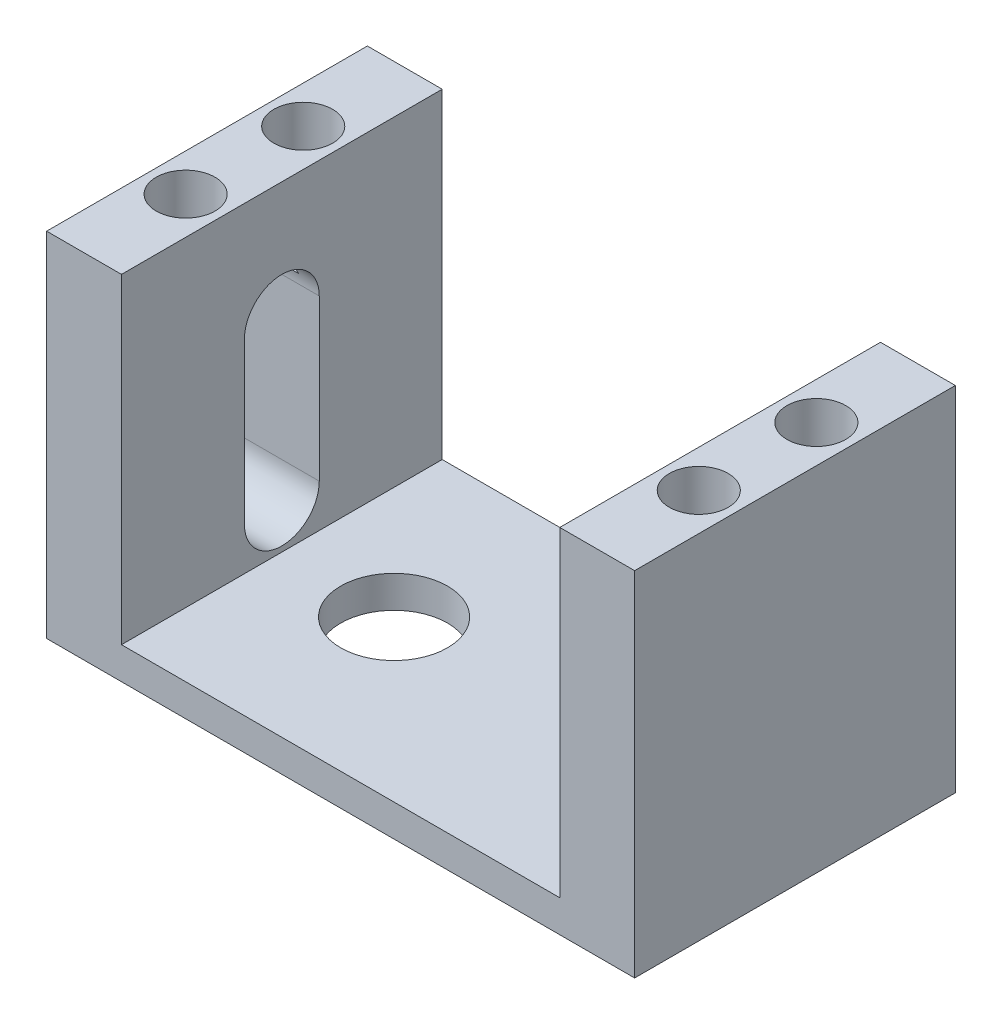
from build123d import *

# Parameters (mm, degrees)
SKETCH1_W           = 55
SKETCH1_H           = 30
BOSS_EXTRUDE1_DEPTH = 3
SKETCH2_W           = 7
SKETCH2_H           = 30
BOSS_EXTRUDE2_DEPTH = 30
SKETCH3_R           = 2.75
CUT_EXTRUDE1_DEPTH  = 10
CUT_EXTRUDE2_REACH  = 57
CUT_EXTRUDE3_REACH  = 35
SKETCH5_R           = 5


with BuildPart() as part:
    # Sketch1 → Boss-Extrude1 (new body)
    with BuildSketch(Plane(origin=(0, 0, 0), x_dir=(1, 0, 0), z_dir=(0, 1, 0))):
        Rectangle(SKETCH1_W, SKETCH1_H)
    extrude(amount=BOSS_EXTRUDE1_DEPTH)

    # Sketch2 → Boss-Extrude2 (add)
    with BuildSketch(Plane(origin=(0, 3, 0), x_dir=(1, 0, 0), z_dir=(0, 1, 0))):
        Polygon((-27.5, -12), (-27.5, -15), (-20.5, -15), (-20.5, 15), (-27.5, 15), align=None)
        with Locations((24, 0)):
            Rectangle(SKETCH2_W, SKETCH2_H)
    extrude(amount=BOSS_EXTRUDE2_DEPTH)

    # Sketch3 → Cut-Extrude1 (cut)
    with BuildSketch(Plane(origin=(0, 33, 0), x_dir=(1, 0, 0), z_dir=(0, 1, 0))):
        with Locations((-24, 5.5)):
            Circle(SKETCH3_R)
        with Locations((-24, -5.5)):
            Circle(SKETCH3_R)
        with Locations((24, -5.5)):
            Circle(SKETCH3_R)
        with Locations((24, 5.5)):
            Circle(SKETCH3_R)
    extrude(amount=-CUT_EXTRUDE1_DEPTH, mode=Mode.SUBTRACT)

    # Sketch4 → Cut-Extrude2 (cut, up to next)
    with BuildSketch(Plane.ZY.offset(27.5), mode=Mode.PRIVATE) as cut_extrude2_sk1:
        with BuildLine():
            Line((3.5, 22), (3.5, 7))
            ThreePointArc((3.5, 7), (0, 3.5), (-3.5, 7))
            Line((-3.5, 7), (-3.5, 22))
            ThreePointArc((-3.5, 22), (0, 25.5), (3.5, 22))
        make_face()
    cut_extrude2_tool1 = extrude(cut_extrude2_sk1.sketch, amount=-CUT_EXTRUDE2_REACH, mode=Mode.PRIVATE) & part.part
    add(cut_extrude2_tool1.solids().sort_by_distance((-27.5, 14.5, 0))[0], mode=Mode.SUBTRACT)

    # Sketch5 → Cut-Extrude3 (cut, up to next)
    with BuildSketch(Plane.XZ, mode=Mode.PRIVATE) as cut_extrude3_sk1:
        with Locations((-10, 0)):
            Circle(SKETCH5_R)
    cut_extrude3_tool1 = extrude(cut_extrude3_sk1.sketch, amount=-CUT_EXTRUDE3_REACH, mode=Mode.PRIVATE) & part.part
    add(cut_extrude3_tool1.solids().sort_by_distance((-10, 0, 0))[0], mode=Mode.SUBTRACT)


solid = part.part
